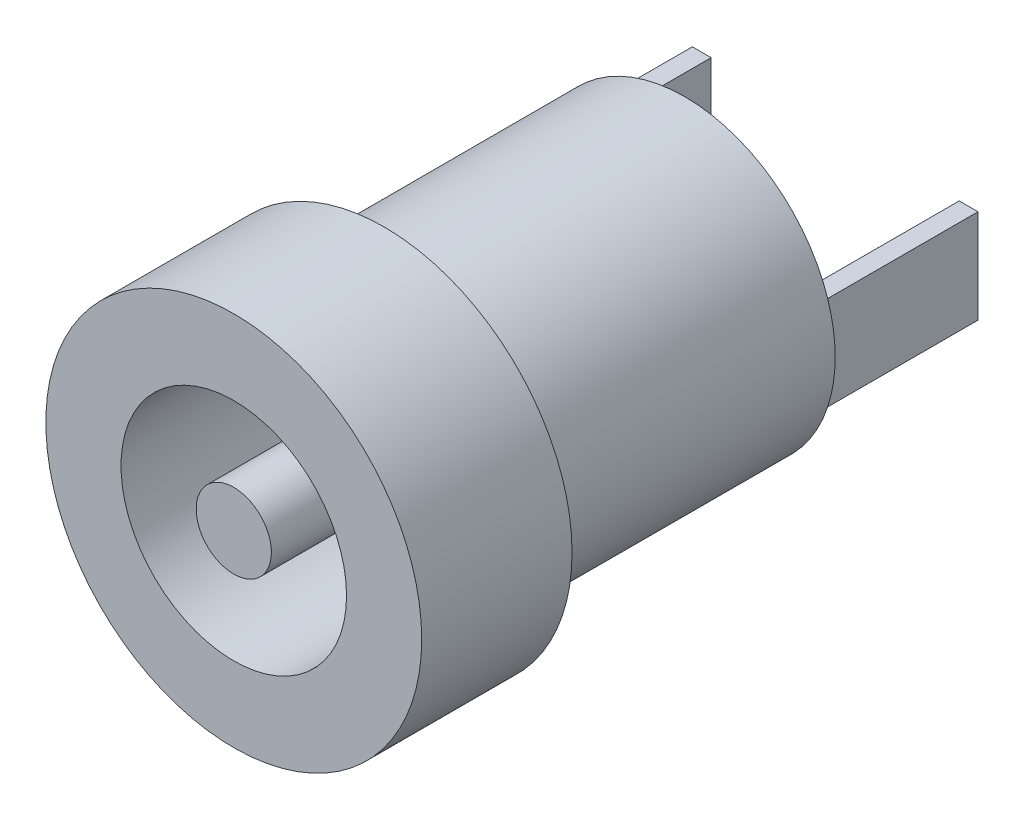
from build123d import *

# Parameters (mm, degrees)
SKETCH1_R             = 5
SKETCH1_R_2           = 3
BOSS_EXTRUDE1_DEPTH   = 4
SKETCH1_R_3           = 1
BOSS_EXTRUDE1_2_DEPTH = 4
SKETCH2_R             = 4
BOSS_EXTRUDE2_DEPTH   = 8
SKETCH3_W             = 0.5
SKETCH3_H             = 2.4979992
BOSS_EXTRUDE3_DEPTH   = 4


with BuildPart() as part:
    # Sketch1 → Boss-Extrude1 (new body)
    with BuildSketch(Plane.XY):
        Circle(SKETCH1_R)
        Circle(SKETCH1_R_2, mode=Mode.SUBTRACT)
    extrude(amount=-BOSS_EXTRUDE1_DEPTH)



with BuildPart() as body_2:
    # Sketch1 → Boss-Extrude1 2 (new body)
    with BuildSketch(Plane.XY):
        Circle(SKETCH1_R_3)
    extrude(amount=-BOSS_EXTRUDE1_2_DEPTH)


with BuildPart() as part_1:
    add(part.part)

    add(body_2.part)  # Boss-Extrude2 merges body 2
    # Sketch2 → Boss-Extrude2 (add)
    with BuildSketch(Plane(origin=(0, 0, -4), x_dir=(-1, 0, 0), z_dir=(0, 0, -1))):
        Circle(SKETCH2_R)
    extrude(amount=BOSS_EXTRUDE2_DEPTH)

    # Sketch3 → Boss-Extrude3 (add)
    with BuildSketch(Plane(origin=(0, 0, -12), x_dir=(-1, 0, 0), z_dir=(0, 0, -1))):
        with Locations((-3.55, 0)):
            Rectangle(SKETCH3_W, SKETCH3_H)
        with Locations((3.55, 0)):
            Rectangle(SKETCH3_W, SKETCH3_H)
    extrude(amount=BOSS_EXTRUDE3_DEPTH)


solid = part_1.part
